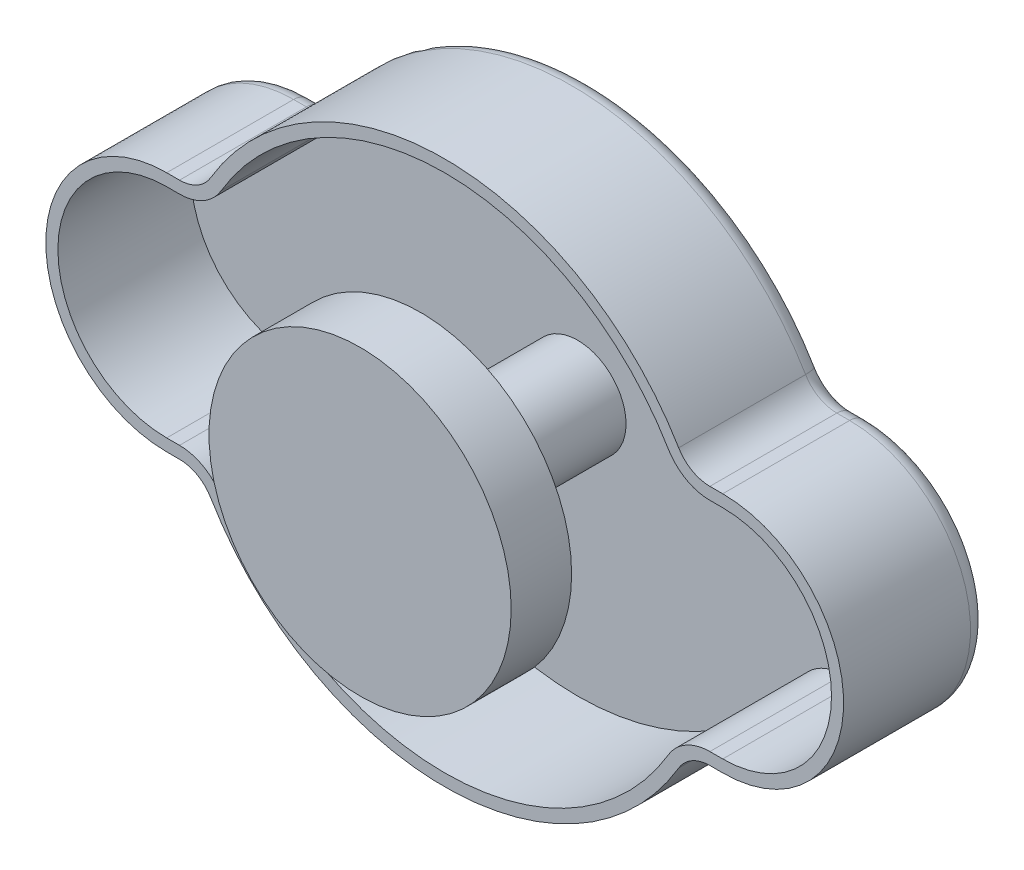
from build123d import *

# Parameters (mm, degrees)
DODANIE_WYCI_GNI_CIE1_DEPTH = 12
ZAOKR_GLENIE1_R             = 3
SKORUPA1_T                  = -1
SZKIC2_R                    = 4
DODANIE_WYCI_GNI_CIE2_DEPTH = 18
SZKIC3_R                    = 12.5
DODANIE_WYCI_GNI_CIE3_DEPTH = 5
SKORUPA2_T                  = -1
ZAOKR_GLENIE2_R             = 1.5


with BuildPart() as part:
    # Szkic1 → Dodanie-wyciągnięcie1 (new body)
    with BuildSketch(Plane.XY):
        with BuildLine():
            Line((-20.155644371, 10), (-23, 10))
            ThreePointArc((-23, 10), (-33, 0), (-23, -10))
            Line((-23, -10), (-20.155644371, -10))
            ThreePointArc((-20.155644371, -10), (0, -22.5), (20.155644371, -10))
            Line((20.155644371, -10), (23, -10))
            ThreePointArc((23, -10), (33, 0), (23, 10))
            Line((23, 10), (20.155644371, 10))
            ThreePointArc((20.155644371, 10), (0, 22.5), (-20.155644371, 10))
        make_face()
    extrude(amount=DODANIE_WYCI_GNI_CIE1_DEPTH)

    # Zaokrąglenie1
    zaokr_glenie1_edges = [part.edges().sort_by_distance(p)[0] for p in [
        (20.155644371, 10, 6),
        (20.155644371, -10, 6),
        (-20.155644371, -10, 6),
        (-20.155644371, 10, 6),
    ]]
    fillet(zaokr_glenie1_edges, radius=ZAOKR_GLENIE1_R)

    # Skorupa1
    skorupa1_openings = [part.faces().sort_by_distance(p)[0] for p in [
        (0, 0, 12),
    ]]
    offset(amount=SKORUPA1_T, openings=skorupa1_openings, kind=Kind.INTERSECTION)

    # Szkic2 → Dodanie-wyciągnięcie2 (add)
    with BuildSketch(Plane.XY.offset(1)):
        Circle(SZKIC2_R)
    extrude(amount=DODANIE_WYCI_GNI_CIE2_DEPTH)

    # Zaokrąglenie2
    zaokr_glenie2_edges = [part.edges().sort_by_distance(p)[0] for p in [
        (-22.468705484, -10, 0),
        (-33, 0, 0),
        (0, -22.5, 0),
        (22.468705484, -10, 0),
        (0, 22.5, 0),
        (-22.468705484, 10, 0),
        (-20.452189654, -10.393447172, 0),
        (20.452189654, -10.393447172, 0),
        (20.452189654, 10.393447172, 0),
        (-20.452189654, 10.393447172, 0),
        (22.468705484, 10, 0),
        (33, 0, 0),
    ]]
    fillet(zaokr_glenie2_edges, radius=ZAOKR_GLENIE2_R)


with BuildPart() as body_2:
    # Szkic3 → Dodanie-wyciągnięcie3 (new body)
    with BuildSketch(Plane.XY.offset(19)):
        Circle(SZKIC3_R)
    extrude(amount=-DODANIE_WYCI_GNI_CIE3_DEPTH)

    # Skorupa2
    skorupa2_openings = [body_2.faces().sort_by_distance(p)[0] for p in [
        (0, 0, 14),
    ]]
    offset(amount=SKORUPA2_T, openings=skorupa2_openings, kind=Kind.INTERSECTION)


solid = Compound([part.part, body_2.part])
